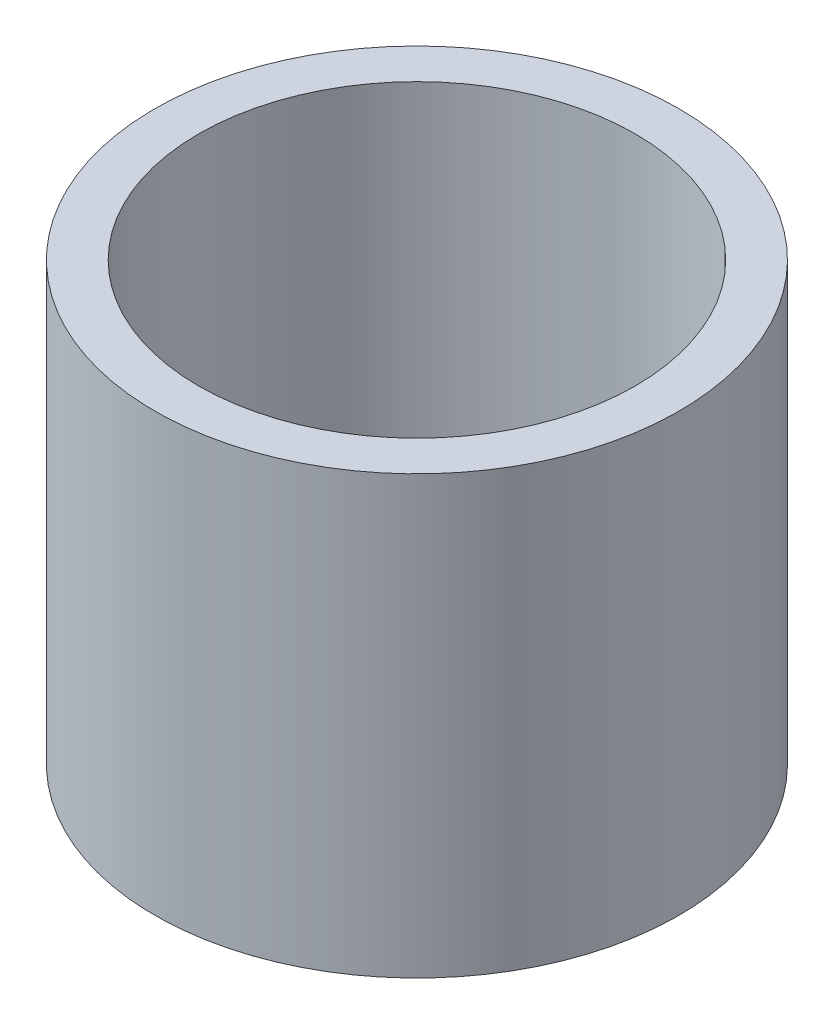
from build123d import *

# Parameters (mm, degrees)
ESQUISSE1_W = 1
ESQUISSE1_H = 10


with BuildPart() as part:
    # Esquisse1 → Révolution1 (revolve)
    with BuildSketch(Plane.XY):
        with Locations((-5.5, 5)):
            Rectangle(ESQUISSE1_W, ESQUISSE1_H)
    revolve(axis=Axis((0, -15.887755102, 0), (0, 1, 0)))


solid = part.part
